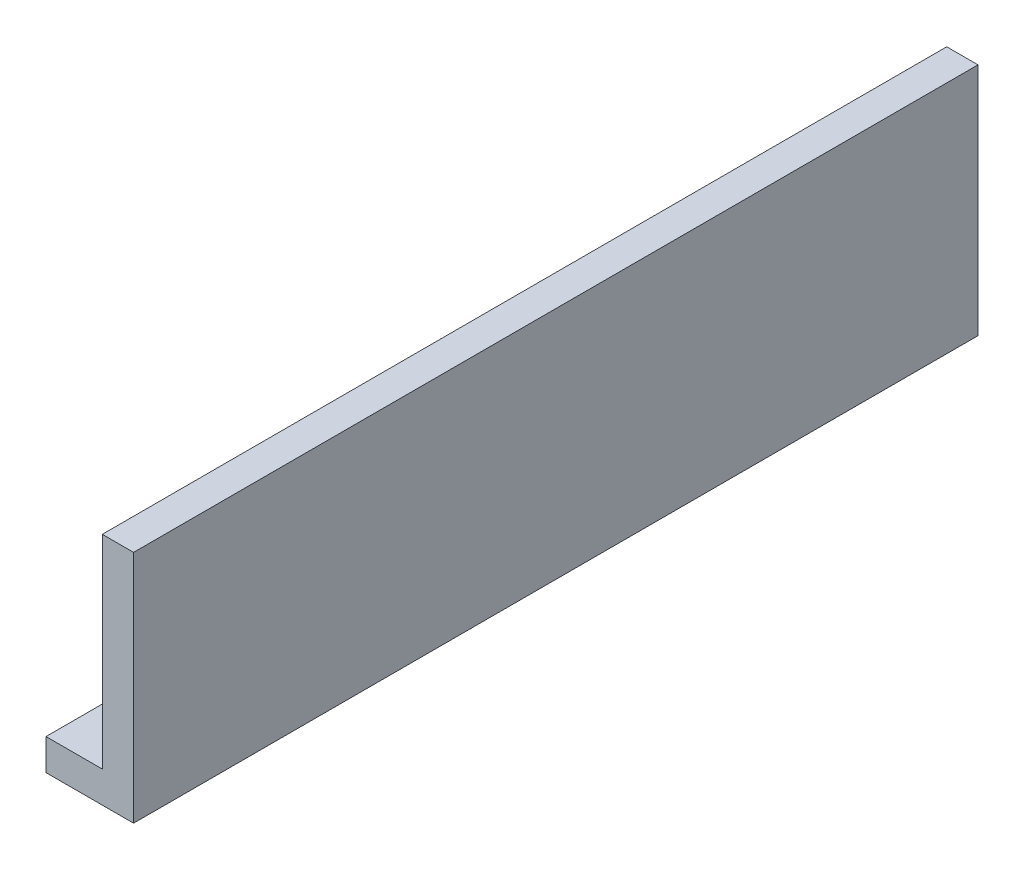
from build123d import *

# Parameters (mm, degrees)
SKETCH1_W           = 20
SKETCH1_H           = 540
BOSS_EXTRUDE1_DEPTH = 150
SKETCH2_W           = 540
SKETCH2_H           = 20
BOSS_EXTRUDE2_DEPTH = 36
M10_TAPPED_HOLE1_D  = 8.5


with BuildPart() as part:
    # Sketch1 → Boss-Extrude1 (new body)
    with BuildSketch(Plane(origin=(0, 0, 0), x_dir=(1, 0, 0), z_dir=(0, 1, 0))):
        with Locations((10, 0)):
            Rectangle(SKETCH1_W, SKETCH1_H)
    extrude(amount=BOSS_EXTRUDE1_DEPTH)

    # Sketch2 → Boss-Extrude2 (add)
    with BuildSketch(Plane(origin=(0, 0, 0), x_dir=(0, 0, -1), z_dir=(1, 0, 0))):
        with Locations((0, 10)):
            Rectangle(SKETCH2_W, SKETCH2_H)
    extrude(amount=-BOSS_EXTRUDE2_DEPTH)

    # M10 Tapped Hole1 (through all)
    with Locations(Plane(origin=(-16, 150, -240), x_dir=(0, 0, 1), z_dir=(0, 1, 0))):
        with Locations((0, 0), (80, 0), (160, 0)):
            m10_tapped_hole1 = Hole(M10_TAPPED_HOLE1_D / 2)

    # Mirror1: M10 Tapped Hole1 across plane
    add(m10_tapped_hole1.mirror(Plane.XY), mode=Mode.SUBTRACT)


solid = part.part
